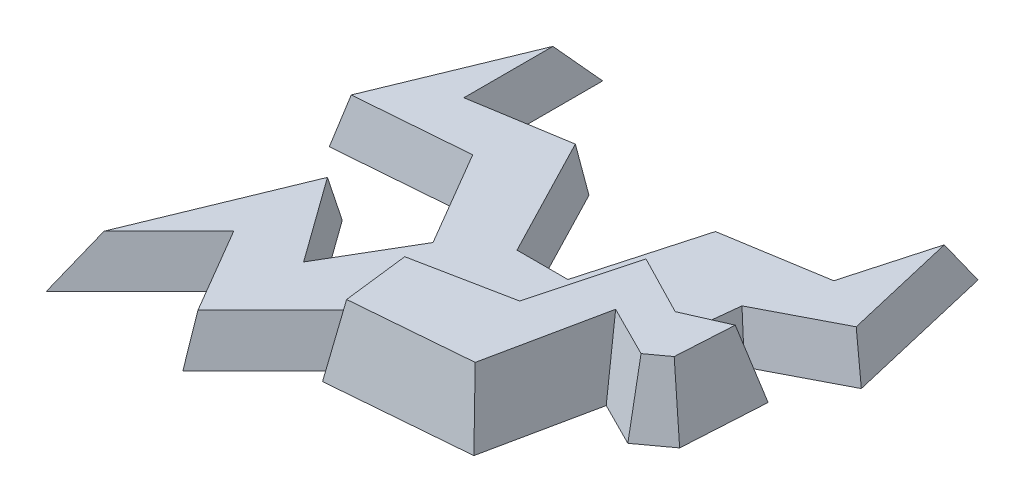
from build123d import *

# Parameters (mm, degrees)
BOSS_EXTRUDE1_DEPTH = 3
BOSS_EXTRUDE1_TAPER = 10
BOSS_EXTRUDE2_DEPTH = 2
BOSS_EXTRUDE2_TAPER = 10


with BuildPart() as part:
    # Sketch2 → Boss-Extrude1 (new body)
    with BuildSketch(Plane(origin=(0, 0, 0), x_dir=(1, 0, 0), z_dir=(0, 1, 0))):
        Polygon((-6.386366525, -1.110831431), (-0.387798033, -0.615752137), (0.59137661, 4.085386129), (2.457892532, 3.146450407), (3.742032583, 4.085386129), (3.950183343, 7.673476682), (1.599090403, 6.641871716), (-1.348493634, 8.160405965), (-2.574910007, 3.568032251), (-6.847574096, 2.717928997), align=None)
    extrude(amount=BOSS_EXTRUDE1_DEPTH, taper=BOSS_EXTRUDE1_TAPER)

    # Sketch3 → Boss-Extrude2 (add)
    with BuildSketch(Plane(origin=(0, 0, 0), x_dir=(1, 0, 0), z_dir=(0, 1, 0))):
        Polygon((-5.401087621, 0.680652537), (-2.497796972, 1.423254114), (-0.865421032, 5.393686332), (1.865812166, 6.033995954), (2.128878959, 8.477950768), (5.434208616, 10.189724535), (3.900877599, 16.730130038), (2.555533764, 11.918695826), (-1.811645648, 11.207975664), (-3.183948296, 6.300127023), (-4.885000457, 6.300127023), (-7.59341425, 11.529907155), (-11.549774725, 10.886044173), (-11.549774725, 16.075722368), (-14.967956792, 7.761669285), (-9.785740879, 8.17089321), (-7.59341425, 4.429360837), (-9.268342977, 1.57485978), (-11.95607608, 5.305249812), (-15.660076801, -3.704000721), (-11.95607608, 0), (-9.785740879, -3.704000721), align=None)
    extrude(amount=BOSS_EXTRUDE2_DEPTH, taper=BOSS_EXTRUDE2_TAPER)


solid = part.part
